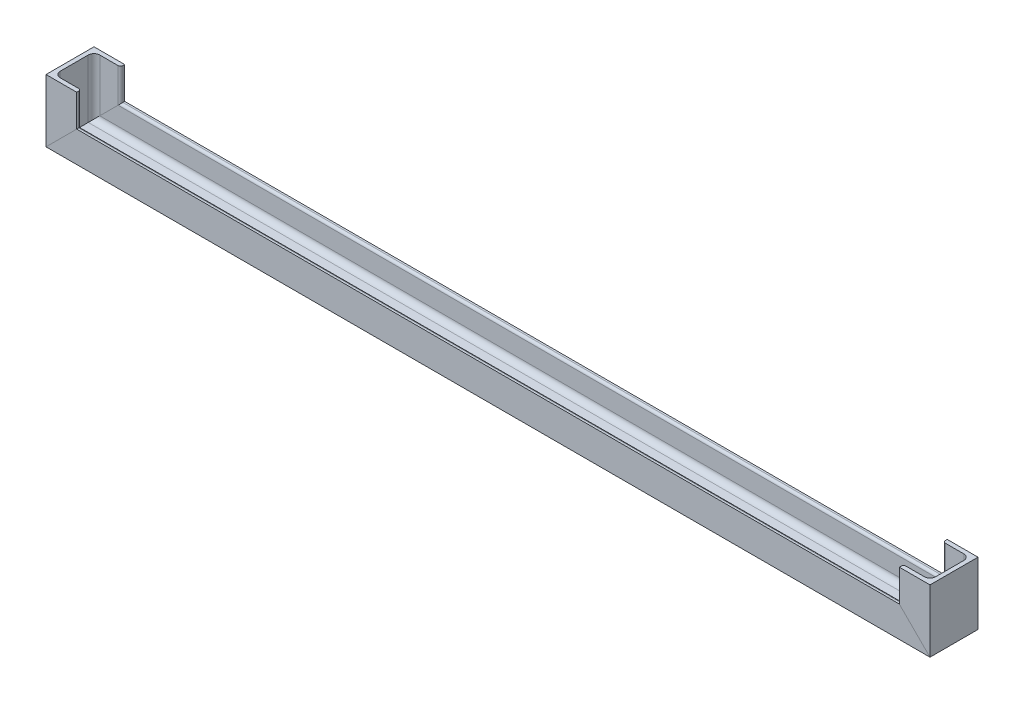
from build123d import *


with BuildPart() as part:
    # По траектории4: sweep along a curve in space
    with BuildLine() as sweep_4_path:
        Line((-460.4, 69.25, 0), (-460.4, 4, 0))
        Line((-460.4, 4, 0), (0, 4, 0))
    # Эскиз2<3> → По траектории4 (sweep)
    with BuildSketch(Plane.XZ.offset(-69.25)):
        with BuildLine():
            Line((-460.4, -25), (-460.4, 25))
            Line((-460.4, 25), (-428.4, 25))
            Line((-428.4, 25), (-428.4, 23.1))
            ThreePointArc((-428.4, 23.1), (-429.132233047, 21.332233047), (-430.9, 20.6))
            Line((-430.9, 20.6), (-450, 20.6))
            ThreePointArc((-450, 20.6), (-454.242640687, 18.842640687), (-456, 14.6))
            Line((-456, 14.6), (-456, -14.6))
            ThreePointArc((-456, -14.6), (-454.242640687, -18.842640687), (-450, -20.6))
            Line((-450, -20.6), (-430.9, -20.6))
            ThreePointArc((-430.9, -20.6), (-429.132233047, -21.332233047), (-428.4, -23.1))
            Line((-428.4, -23.1), (-428.4, -25))
            Line((-428.4, -25), (-460.4, -25))
        make_face()
    sweep(path=sweep_4_path.line, transition=Transition.RIGHT)

    # Зеркальное отражение2: part across plane


with BuildPart() as part_1:
    add(part.part)
    add(part.part.mirror(Plane(origin=(0, 33.5, 23.1), x_dir=(0, 0, 1), z_dir=(-1, 0, 0))))


solid = part_1.part
